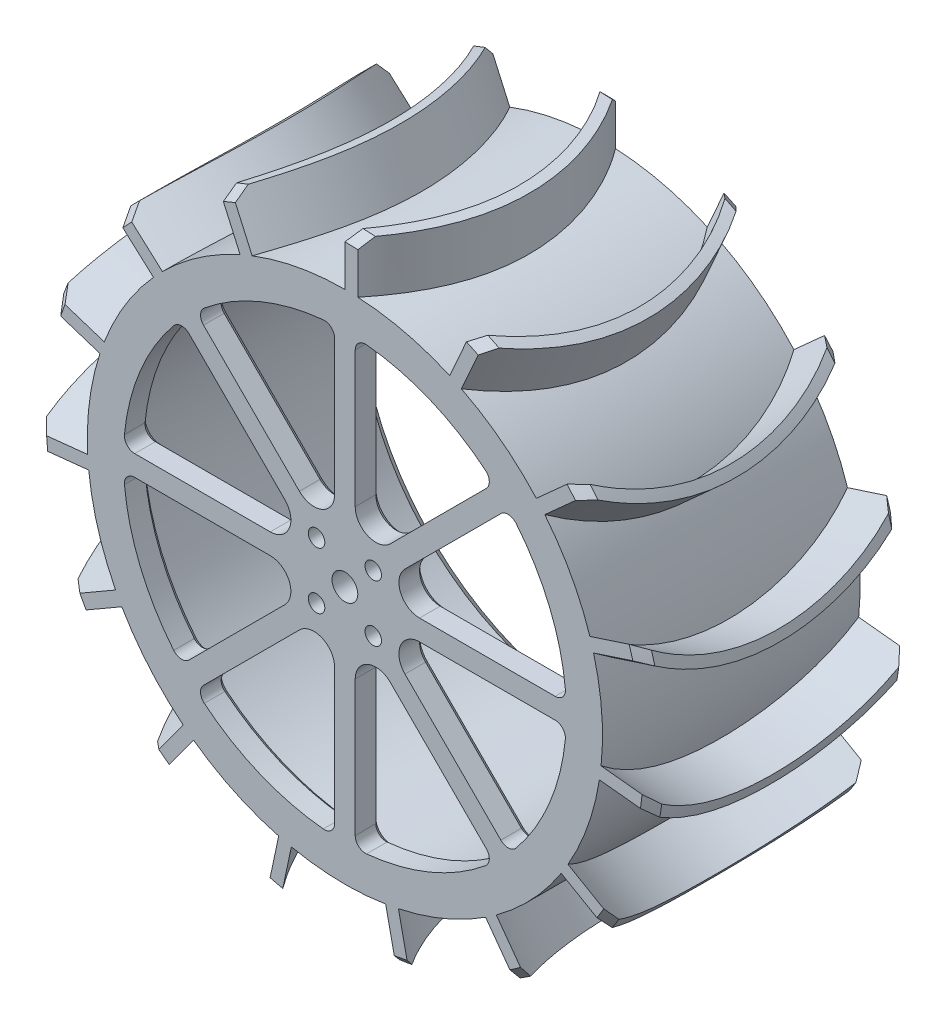
from build123d import *

# Parameters (mm, degrees)
SKETCH1_R                    = 50
BOSS_EXTRUDE1_DEPTH          = 25
BOSS_EXTRUDE2_REACH          = 77
BOSS_EXTRUDE2_END_RADIUS     = 60
CHAMFER1_SIZE                = 2
CIRPATTERN1_COUNT            = 15
CHAMFER1_OF_CIRPATTERN1_SIZE = 2
SKETCH4_R                    = 45
CUT_EXTRUDE1_DEPTH           = 89.446292118
CUT_EXTRUDE1_DEPTH_BACK      = 20
CUT_EXTRUDE2_DEPTH           = 89.446292118
CHAMFER2_SIZE                = 1
CIRPATTERN2_COUNT            = 8
CHAMFER2_OF_CIRPATTERN2_SIZE = 1
SKETCH2_R                    = 1.6
SKETCH2_R_2                  = 2.5
CUT_EXTRUDE3_DEPTH           = 89.446292118
CHAMFER3_SIZE                = 2
CHAMFER4_SIZE                = 1


with BuildPart() as part:
    # Sketch1 → Boss-Extrude1 (new, symmetric)
    with BuildSketch(Plane.XY):
        Circle(SKETCH1_R)
    extrude(amount=BOSS_EXTRUDE1_DEPTH, both=True)

    # Boss-Extrude2: up to this cylinder (the profile starts inside it)
    boss_extrude2_end = Plane(origin=(0, 0, 24.488522), z_dir=(0, 0, -1)) * Cylinder(BOSS_EXTRUDE2_END_RADIUS, 275, mode=Mode.PRIVATE)
    # Sketch3 → Boss-Extrude2 (add, up to the surface)
    with BuildSketch(Plane(origin=(0, 0, 0), x_dir=(1, 0, 0), z_dir=(0, 1, 0)), mode=Mode.PRIVATE) as boss_extrude2_sk1:
        with BuildLine():
            ThreePointArc((0, 25), (8.775010008, 0), (0, -25))
            Line((0, -25), (2.524084069, -25))
            ThreePointArc((2.524084069, -25), (10.775010008, 0), (2.524084069, 25))
            Line((2.524084069, 25), (0, 25))
        make_face()
    boss_extrude2_tool1 = extrude(boss_extrude2_sk1.sketch, amount=BOSS_EXTRUDE2_REACH, mode=Mode.PRIVATE) & boss_extrude2_end
    boss_extrude2 = boss_extrude2_tool1.solids().sort_by_distance((1.262042, 0, 24.488522))[0]
    add(boss_extrude2)

    # Chamfer1
    chamfer1_edges = [part.edges().sort_by_distance(p)[0] for p in [
        (1.262321434, 59.986719735, -25),
        (1.262321434, 59.986719735, 25),
    ]]
    chamfer(chamfer1_edges, length=CHAMFER1_SIZE)

    # CirPattern1: Boss-Extrude2 ×15 about axis
    cirpattern1_axis = Axis((0, 0, 0), (0, 0, 1))
    for i in range(1, CIRPATTERN1_COUNT):
        add(boss_extrude2.rotate(cirpattern1_axis, i * 360 / CIRPATTERN1_COUNT))

    # Chamfer1 of CirPattern1
    chamfer1_of_cirpattern1_edges = [part.edges().sort_by_distance(p)[0] for p in [
        (-23.245609002, 55.314027716, -25),
        (-23.245609002, 55.314027716, 25),
        (-43.734162462, 41.077037792, -25),
        (-43.734162462, 41.077037792, 25),
        (-56.66068192, 19.737454861, -25),
        (-56.66068192, 19.737454861, 25),
        (-59.790054728, -5.014913325, -25),
        (-59.790054728, -5.014913325, 25),
        (-52.581183897, -28.900157438, -25),
        (-52.581183897, -28.900157438, 25),
        (-36.280548686, -47.78830178, -25),
        (-36.280548686, -47.78830178, 25),
        (-13.706677009, -58.413414601, -25),
        (-13.706677009, -58.413414601, 25),
        (11.237203645, -58.938317369, -25),
        (11.237203645, -58.938317369, 25),
        (34.238069701, -49.272249625, -25),
        (34.238069701, -49.272249625, 25),
        (51.318862463, -31.086562297, -25),
        (51.318862463, -31.086562297, 25),
        (59.526157688, -7.525725936, -25),
        (59.526157688, -7.525725936, 25),
        (57.440839471, 17.336376809, -25),
        (57.440839471, 17.336376809, 25),
        (45.423478275, 39.200862508, -25),
        (45.423478275, 39.200862508, 25),
        (25.551985026, 54.28716295, -25),
        (25.551985026, 54.28716295, 25),
    ]]
    chamfer(chamfer1_of_cirpattern1_edges, length=CHAMFER1_OF_CIRPATTERN1_SIZE)

    # Sketch4 → Cut-Extrude1 (cut, two sides)
    with BuildSketch(Plane.XY) as cut_extrude1_sk:
        Circle(SKETCH4_R)
    extrude(amount=CUT_EXTRUDE1_DEPTH, mode=Mode.SUBTRACT)
    extrude(cut_extrude1_sk.sketch, amount=-CUT_EXTRUDE1_DEPTH_BACK, mode=Mode.SUBTRACT)

    # Sketch4_3 → Cut-Extrude2 (cut, through all)
    with BuildSketch(Plane.XY):
        with BuildLine():
            ThreePointArc((-27.294144039, 33.226942399), (-16.455387592, 39.726819898), (-4.195121951, 42.794870625))
            ThreePointArc((-4.195121951, 42.794870625), (-2.656542502, 42.286005921), (-2, 40.804411526))
            Line((-2, 40.804411526), (-2, 14.485281374))
            ThreePointArc((-2, 14.485281374), (-4.469266271, 10.789763244), (-8.828427125, 11.656854249))
            Line((-8.828427125, 11.656854249), (-27.43886253, 30.267289655))
            ThreePointArc((-27.43886253, 30.267289655), (-28.022262318, 31.779180754), (-27.294144039, 33.226942399))
        make_face()
    cut_extrude2 = extrude(amount=-CUT_EXTRUDE2_DEPTH, mode=Mode.SUBTRACT)

    # Chamfer2
    chamfer2_edges = [part.edges().sort_by_distance(p)[0] for p in [
        (-28.022262318, 31.779180754, -20),
        (-18.133644827, 20.962071952, -20),
        (-4.469266271, 10.789763244, -20),
        (-2, 27.64484645, -20),
        (-2.656542502, 42.286005921, -20),
        (-16.455387592, 39.726819898, -20),
    ]]
    chamfer(chamfer2_edges, length=CHAMFER2_SIZE)

    # CirPattern2: Cut-Extrude2 ×8 about axis
    cirpattern2_axis = Axis((0, 0, 0), (0, 0, 1))
    for i in range(1, CIRPATTERN2_COUNT):
        add(cut_extrude2.rotate(cirpattern2_axis, i * 360 / CIRPATTERN2_COUNT), mode=Mode.SUBTRACT)

    # Chamfer2 of CirPattern2
    chamfer2_of_cirpattern2_edges = [part.edges().sort_by_distance(p)[0] for p in [
        (-42.286005921, 2.656542502, -20),
        (-27.64484645, 2, -20),
        (-10.789763244, 4.469266271, -20),
        (-20.962071952, 18.133644827, -20),
        (-31.779180754, 28.022262318, -20),
        (-39.726819898, 16.455387592, -20),
        (-31.779180754, -28.022262318, -20),
        (-20.962071952, -18.133644827, -20),
        (-10.789763244, -4.469266271, -20),
        (-27.64484645, -2, -20),
        (-42.286005921, -2.656542502, -20),
        (-39.726819898, -16.455387592, -20),
        (-2.656542502, -42.286005921, -20),
        (-2, -27.64484645, -20),
        (-4.469266271, -10.789763244, -20),
        (-18.133644827, -20.962071952, -20),
        (-28.022262318, -31.779180754, -20),
        (-16.455387592, -39.726819898, -20),
        (28.022262318, -31.779180754, -20),
        (18.133644827, -20.962071952, -20),
        (4.469266271, -10.789763244, -20),
        (2, -27.64484645, -20),
        (2.656542502, -42.286005921, -20),
        (16.455387592, -39.726819898, -20),
        (42.286005921, -2.656542502, -20),
        (27.64484645, -2, -20),
        (10.789763244, -4.469266271, -20),
        (20.962071952, -18.133644827, -20),
        (31.779180754, -28.022262318, -20),
        (39.726819898, -16.455387592, -20),
        (31.779180754, 28.022262318, -20),
        (20.962071952, 18.133644827, -20),
        (10.789763244, 4.469266271, -20),
        (27.64484645, 2, -20),
        (42.286005921, 2.656542502, -20),
        (39.726819898, 16.455387592, -20),
        (2.656542502, 42.286005921, -20),
        (2, 27.64484645, -20),
        (4.469266271, 10.789763244, -20),
        (18.133644827, 20.962071952, -20),
        (28.022262318, 31.779180754, -20),
        (16.455387592, 39.726819898, -20),
    ]]
    chamfer(chamfer2_of_cirpattern2_edges, length=CHAMFER2_OF_CIRPATTERN2_SIZE)

    # Sketch2 → Cut-Extrude3 (cut, through all)
    with BuildSketch(Plane.XY):
        with Locations((5.5, 5.5)):
            Circle(SKETCH2_R)
        with Locations((-5.5, 5.5)):
            Circle(SKETCH2_R)
        with Locations((-5.5, -5.5)):
            Circle(SKETCH2_R)
        with Locations((5.5, -5.5)):
            Circle(SKETCH2_R)
        Circle(SKETCH2_R_2)
    extrude(amount=-CUT_EXTRUDE3_DEPTH, mode=Mode.SUBTRACT)

    # Chamfer3
    chamfer3_edges = [part.edges().sort_by_distance(p)[0] for p in [
        (-45, 0, 25),
    ]]
    chamfer(chamfer3_edges, length=CHAMFER3_SIZE)

    # Chamfer4
    chamfer4_edges = [part.edges().sort_by_distance(p)[0] for p in [
        (-2.5, 0, -20),
    ]]
    chamfer(chamfer4_edges, length=CHAMFER4_SIZE)


with BuildPart() as body_2:
    # Mirror1: mirrored copy
    add(part.part.mirror(Plane.XY))


solid = body_2.part
